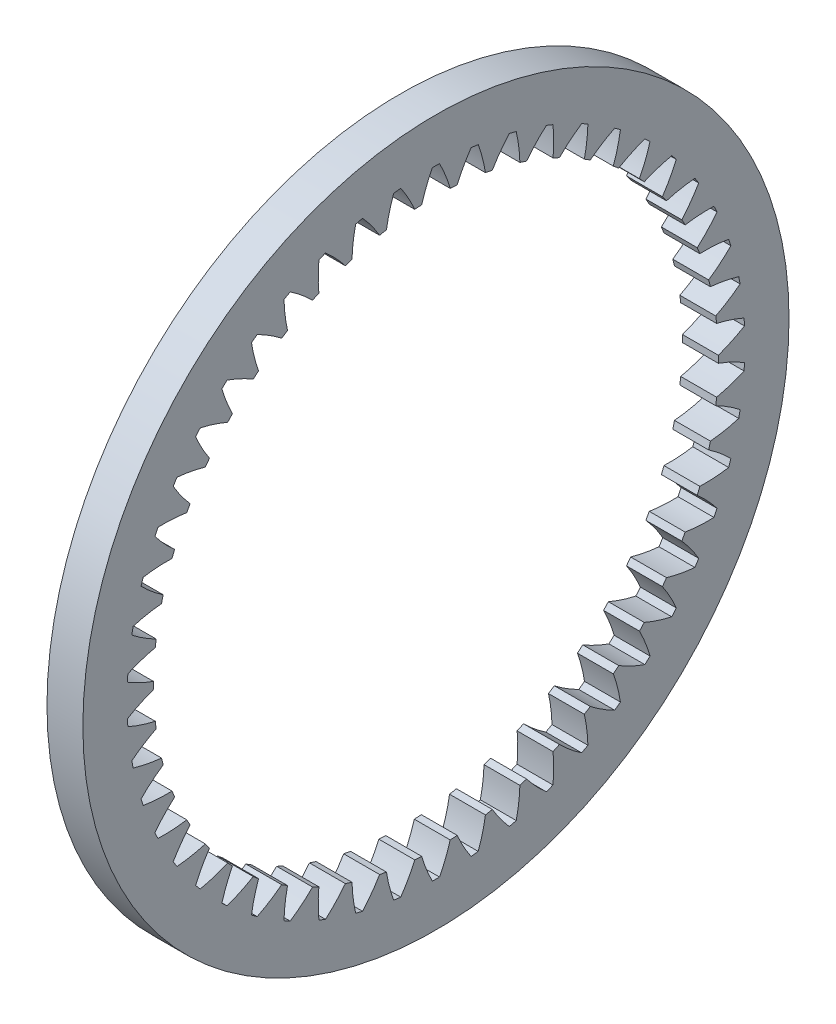
from build123d import *

# Parameters (mm, degrees)
BASPROSKE_W     = 6.1
BASPROSKE_H     = 12
TOOTHCUT_DEPTH  = 86.07179321
TEETHCUTS_COUNT = 50
TEETHCUTS_ANGLE = 352.8


with BuildPart() as part:
    # BasProSke → Base-Revolve (revolve)
    with BuildSketch(Plane(origin=(0, 0, 0), x_dir=(1, 0, 0), z_dir=(0, 1, 0))):
        with Locations((3.05, 54)):
            Rectangle(BASPROSKE_W, BASPROSKE_H)
    revolve(axis=Axis((-10, 0, 0), (1, 0, 0)))

    # TooCutSke → ToothCut (cut, through all)
    with BuildSketch(Plane(origin=(0, 0, 0), x_dir=(0, 0, -1), z_dir=(1, 0, 0))):
        with BuildLine():
            ThreePointArc((2.426707814, 47.913185391), (1.628356337, 50.250450788), (0.603274723, 52.497533853))
            ThreePointArc((0.603274723, 52.497533853), (0, 52.501), (-0.603274723, 52.497533853))
            ThreePointArc((-0.603274723, 52.497533853), (-1.628356337, 50.250450788), (-2.426707814, 47.913185391))
            ThreePointArc((-2.426707814, 47.913185391), (0, 47.9746), (2.426707814, 47.913185391))
        make_face()
    toothcut = extrude(amount=TOOTHCUT_DEPTH, mode=Mode.SUBTRACT)

    # TeethCuts: ToothCut ×50 about axis
    teethcuts_axis = Axis((-10, 0, 0), (1, 0, 0))
    for i in range(1, TEETHCUTS_COUNT):
        add(toothcut.rotate(teethcuts_axis, i * TEETHCUTS_ANGLE / (TEETHCUTS_COUNT - 1)), mode=Mode.SUBTRACT)


solid = part.part
